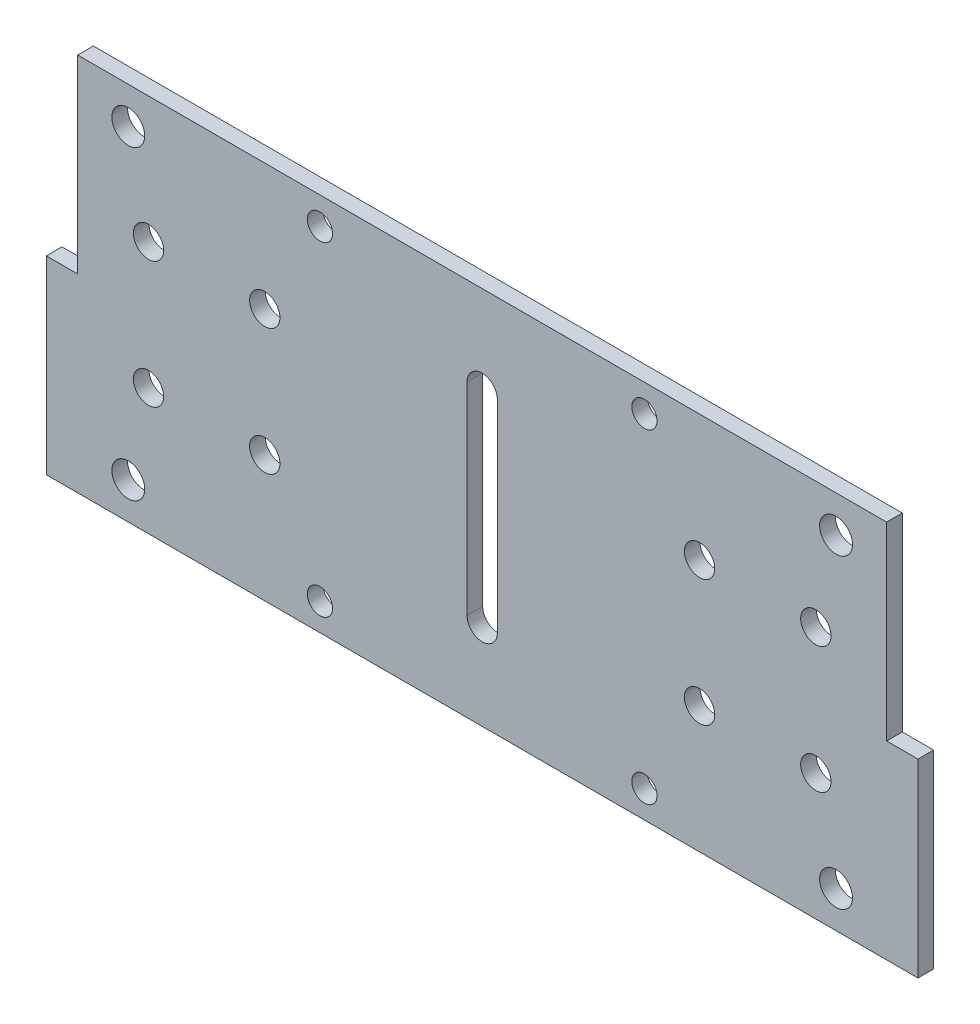
from build123d import *

# Parameters (mm, degrees)
SKETCH1_W           = 160
SKETCH1_H           = 75
BOSS_EXTRUDE1_DEPTH = 3.1
SKETCH2_W           = 6.2
SKETCH2_H           = 37.5
BOSS_EXTRUDE2_DEPTH = 3.1
SKETCH3_R           = 2.5
SKETCH3_R_2         = 3
SKETCH3_R_3         = 3.25
CUT_EXTRUDE1_DEPTH  = 4.1


with BuildPart() as part:
    # Sketch1 → Boss-Extrude1 (new body)
    with BuildSketch(Plane.XY):
        Rectangle(SKETCH1_W, SKETCH1_H)
    extrude(amount=BOSS_EXTRUDE1_DEPTH)

    # Sketch2 → Boss-Extrude2 (add, through all)
    with BuildSketch(Plane.XY.offset(3.1)):
        with Locations((83.1, -18.75)):
            Rectangle(SKETCH2_W, SKETCH2_H)
        with Locations((-83.1, -18.75)):
            Rectangle(SKETCH2_W, SKETCH2_H)
    extrude(amount=-BOSS_EXTRUDE2_DEPTH)

    # Sketch3 → Cut-Extrude1 (cut, through all)
    with BuildSketch(Plane.XY.offset(3.1)):
        with Locations((32.08959236, 32.08959236)):
            Circle(SKETCH3_R)
        with Locations((32.08959236, -32.08959236)):
            Circle(SKETCH3_R)
        with Locations((-32.08959236, -32.08959236)):
            Circle(SKETCH3_R)
        with Locations((-32.08959236, 32.08959236)):
            Circle(SKETCH3_R)
        with Locations((-66, 12.5)):
            Circle(SKETCH3_R_2)
        with Locations((-43, 12.5)):
            Circle(SKETCH3_R_2)
        with Locations((-43, -12.5)):
            Circle(SKETCH3_R_2)
        with Locations((-66, -12.5)):
            Circle(SKETCH3_R_2)
        with Locations((43, 12.5)):
            Circle(SKETCH3_R_2)
        with Locations((66, 12.5)):
            Circle(SKETCH3_R_2)
        with Locations((66, -12.5)):
            Circle(SKETCH3_R_2)
        with Locations((43, -12.5)):
            Circle(SKETCH3_R_2)
        with Locations((-70, -30.258810311)):
            Circle(SKETCH3_R_3)
        with Locations((70, -30.258810311)):
            Circle(SKETCH3_R_3)
        with Locations((-70, 30.258810311)):
            Circle(SKETCH3_R_3)
        with Locations((70, 30.258810311)):
            Circle(SKETCH3_R_3)
        with BuildLine():
            Line((3, -20), (3, 20))
            ThreePointArc((3, 20), (0, 23), (-3, 20))
            Line((-3, 20), (-3, -20))
            ThreePointArc((-3, -20), (0, -23), (3, -20))
        make_face()
    extrude(amount=-CUT_EXTRUDE1_DEPTH, mode=Mode.SUBTRACT)


solid = part.part
